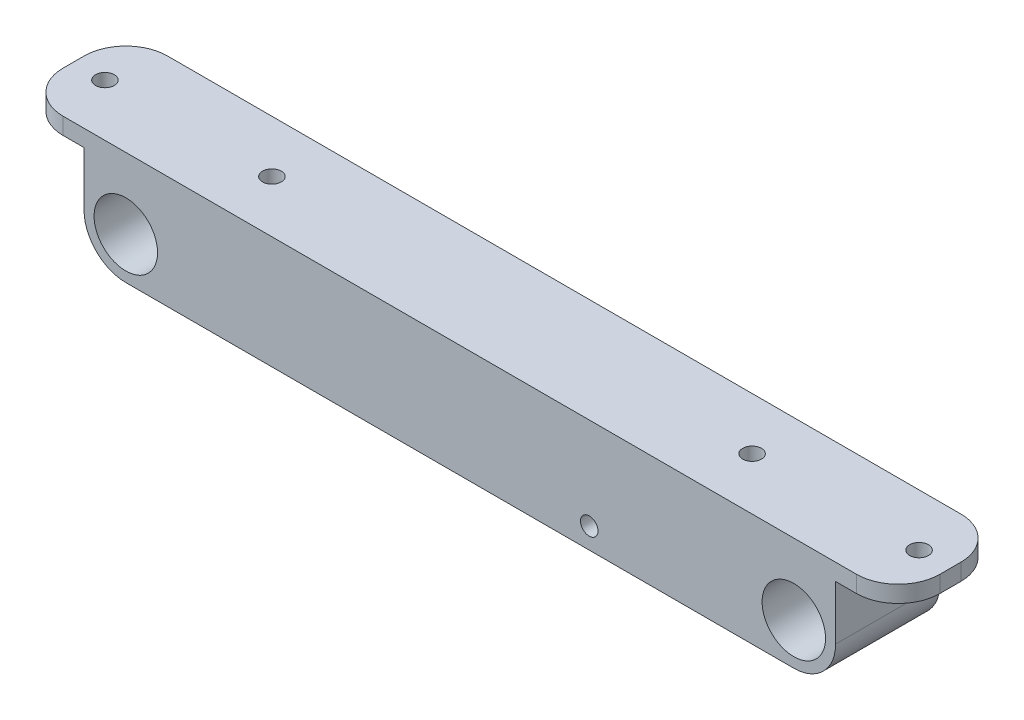
from build123d import *

# Parameters (mm, degrees)
SKETCH1_R            = 7.6
BOSS_EXTRUDE1_DEPTH  = 25
SKETCH2_W            = 30
SKETCH2_H            = 27
BOSS_EXTRUDE2_DEPTH  = 25
SKETCH3_R            = 7.6
BOSS_EXTRUDE3_DEPTH  = 2
CHAMFER1_SIZE        = 5
SKETCH5_W            = 25
SKETCH5_H            = 4
BOSS_EXTRUDE4_DEPTH  = 15
SKETCH6_R            = 2.25
CUT_EXTRUDE2_DEPTH   = 15
FILLET1_R            = 10
FILLET1_OF_MIRROR2_R = 10
SKETCH7_R            = 2.25
CUT_EXTRUDE3_DEPTH   = 15
CUT_EXTRUDE4_DEPTH   = 15
SKETCH9_R            = 2.1
CUT_EXTRUDE5_DEPTH   = 28.468092804
CUT_EXTRUDE6_DEPTH   = 5


with BuildPart() as part:
    # Sketch1 → Boss-Extrude1 (new body)
    with BuildSketch(Plane.XY):
        with BuildLine():
            Line((-90, 0), (-90, 17))
            Line((-90, 17), (90, 17))
            Line((90, 17), (90, 0))
            ThreePointArc((90, 0), (80, -10), (70, 0))
            Line((70, 0), (70, 13))
            Line((70, 13), (-70, 13))
            Line((-70, 13), (-70, 0))
            ThreePointArc((-70, 0), (-80, -10), (-90, 0))
        make_face()
        with Locations((-80, 0)):
            Circle(SKETCH1_R, mode=Mode.SUBTRACT)
        with Locations((80, 0)):
            Circle(SKETCH1_R, mode=Mode.SUBTRACT)
    extrude(amount=BOSS_EXTRUDE1_DEPTH)

    # Sketch2 → Boss-Extrude2 (add)
    with BuildSketch(Plane(origin=(0, 0, 0), x_dir=(-1, 0, 0), z_dir=(0, 0, -1))):
        with Locations((-31, 3.5)):
            Rectangle(SKETCH2_W, SKETCH2_H)
    extrude(amount=-BOSS_EXTRUDE2_DEPTH)

    # Sketch3 → Boss-Extrude3 (add)
    with BuildSketch(Plane(origin=(0, 0, 0), x_dir=(-1, 0, 0), z_dir=(0, 0, -1))):
        with BuildLine():
            Line((80, -10), (-12, -10))
            Line((-12, -10), (-42, -10))
            Line((-42, -10), (-80, -10))
            ThreePointArc((-80, -10), (-87.071067812, -7.071067812), (-90, 0))
            Line((-90, 0), (-90, 17))
            Line((-90, 17), (90, 17))
            Line((90, 17), (90, 0))
            ThreePointArc((90, 0), (87.071067812, -7.071067812), (80, -10))
        make_face()
        with Locations((80, 0)):
            Circle(SKETCH3_R, mode=Mode.SUBTRACT)
        with Locations((-80, 0)):
            Circle(SKETCH3_R, mode=Mode.SUBTRACT)
    boss_extrude3 = extrude(amount=-BOSS_EXTRUDE3_DEPTH)

    # Mirror1: Boss-Extrude3 across plane
    add(boss_extrude3.mirror(Plane.XY.offset(12.5)))

    # Chamfer1
    chamfer1_edges = [part.edges().sort_by_distance(p)[0] for p in [
        (70, 13, 12.5),
        (-70, 13, 12.5),
    ]]
    chamfer(chamfer1_edges, length=CHAMFER1_SIZE)

    # Sketch5 → Boss-Extrude4 (add)
    with BuildSketch(Plane.ZY.offset(90)):
        with Locations((12.5, 15)):
            Rectangle(SKETCH5_W, SKETCH5_H)
    boss_extrude4 = extrude(amount=BOSS_EXTRUDE4_DEPTH)

    # Sketch6 → Cut-Extrude2 (cut)
    with BuildSketch(Plane(origin=(0, 13, 0), x_dir=(-1, 0, 0), z_dir=(0, -1, 0))):
        with Locations((97.5, -12.5)):
            Circle(SKETCH6_R)
    cut_extrude2 = extrude(amount=-CUT_EXTRUDE2_DEPTH, mode=Mode.SUBTRACT)

    # Fillet1
    fillet1_edges = [part.edges().sort_by_distance(p)[0] for p in [
        (-105, 15, 0),
        (-105, 15, 25),
    ]]
    fillet(fillet1_edges, radius=FILLET1_R)

    # Mirror2: Boss-Extrude4 across plane
    add(boss_extrude4.mirror(Plane(origin=(0, 0, 0), x_dir=(0, 0, 1), z_dir=(1, 0, 0))))

    # Fillet1 of Mirror2
    fillet1_of_mirror2_edges = [part.edges().sort_by_distance(p)[0] for p in [
        (105, 15, 0),
        (105, 15, 25),
    ]]
    fillet(fillet1_of_mirror2_edges, radius=FILLET1_OF_MIRROR2_R)

    # Mirror4: Cut-Extrude2 across plane
    add(cut_extrude2.mirror(Plane(origin=(0, 0, 0), x_dir=(0, 0, 1), z_dir=(1, 0, 0))), mode=Mode.SUBTRACT)

    # Sketch7 → Cut-Extrude3 (cut)
    with BuildSketch(Plane(origin=(0, 17, 0), x_dir=(1, 0, 0), z_dir=(0, 1, 0))):
        with Locations((-57.5, -12.5)):
            Circle(SKETCH7_R)
        with Locations((57.5, -12.5)):
            Circle(SKETCH7_R)
    extrude(amount=-CUT_EXTRUDE3_DEPTH, mode=Mode.SUBTRACT)

    # Sketch8 → Cut-Extrude4 (cut)
    with BuildSketch(Plane.XZ.offset(10)):
        with BuildLine():
            Line((21.95, 19), (20, 19))
            Line((20, 19), (20, 17.05))
            ThreePointArc((20, 17.05), (21.378858223, 17.621141777), (21.95, 19))
        make_face()
        with BuildLine():
            Line((20, 17.05), (20, 19))
            Line((20, 19), (21.95, 19))
            ThreePointArc((21.95, 19), (18.621141777, 20.378858223), (20, 17.05))
        make_face()
        with BuildLine():
            ThreePointArc((43.95, 19), (42, 20.95), (40.05, 19))
            Line((40.05, 19), (42, 19))
            Line((42, 19), (42, 17.05))
            ThreePointArc((42, 17.05), (43.378858223, 17.621141777), (43.95, 19))
        make_face()
        with BuildLine():
            Line((42, 19), (40.05, 19))
            ThreePointArc((40.05, 19), (40.621141777, 17.621141777), (42, 17.05))
            Line((42, 17.05), (42, 19))
        make_face()
        with BuildLine():
            ThreePointArc((42, 7.95), (40.621141777, 7.378858223), (40.05, 6))
            Line((40.05, 6), (42, 6))
            Line((42, 6), (42, 7.95))
        make_face()
        with BuildLine():
            Line((42, 6), (40.05, 6))
            ThreePointArc((40.05, 6), (42, 4.05), (43.95, 6))
            ThreePointArc((43.95, 6), (43.378858223, 7.378858223), (42, 7.95))
            Line((42, 7.95), (42, 6))
        make_face()
        with BuildLine():
            ThreePointArc((21.95, 6), (21.378858223, 7.378858223), (20, 7.95))
            Line((20, 7.95), (20, 6))
            Line((20, 6), (21.95, 6))
        make_face()
        with BuildLine():
            Line((20, 6), (20, 7.95))
            ThreePointArc((20, 7.95), (18.621141777, 4.621141777), (21.95, 6))
            Line((21.95, 6), (20, 6))
        make_face()
    extrude(amount=-CUT_EXTRUDE4_DEPTH, mode=Mode.SUBTRACT)

    # Sketch9 → Cut-Extrude5 (cut)
    with BuildSketch(Plane.XY.offset(25)):
        with Locations((31, -5)):
            Circle(SKETCH9_R)
    extrude(amount=-CUT_EXTRUDE5_DEPTH, mode=Mode.SUBTRACT)

    # Sketch10 → Cut-Extrude6 (cut)
    with BuildSketch(Plane(origin=(0, 0, 0), x_dir=(-1, 0, 0), z_dir=(0, 0, -1))):
        Polygon((-26.669872981, -5), (-28.834936491, -1.25), (-33.165063509, -1.25), (-35.330127019, -5), (-33.165063509, -8.75), (-28.834936491, -8.75), align=None)
    extrude(amount=-CUT_EXTRUDE6_DEPTH, mode=Mode.SUBTRACT)


solid = part.part
